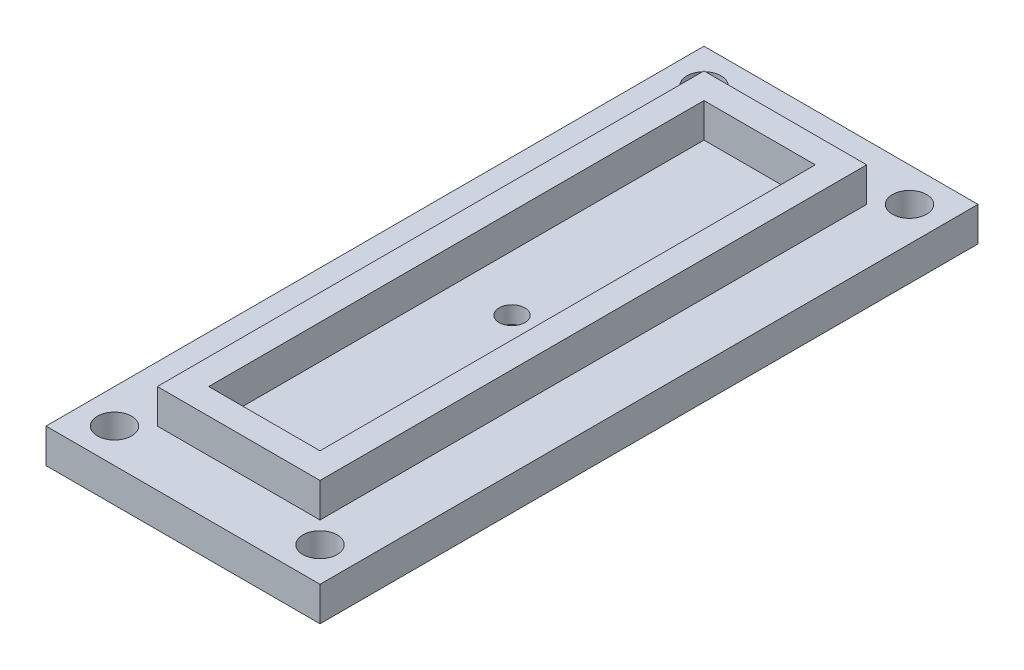
from build123d import *

# Parameters (mm, degrees)
SKETCH1_W               = 16
SKETCH1_H               = 38.42
BOSS_EXTRUDE1_DEPTH     = 2
SKETCH2_W               = 9.5
SKETCH2_H               = 31.92
SKETCH2_W_2             = 6.5
SKETCH2_H_2             = 28.92
EXTRUDE_THIN1_DEPTH     = 2
SKETCH3_R               = 1
CUT_EXTRUDE1_DEPTH      = 22.190188767
MIRROR2_COPY_1_SKETCH_R = 1
MIRROR2_COPY_1_DEPTH    = 22.190188767
MIRROR2_COPY_2_SKETCH_R = 1
MIRROR2_COPY_2_DEPTH    = 22.190188767
CUT_EXTRUDE_THIN1_START = -1
SKETCH2_3_W             = 9.5
SKETCH2_3_H             = 31.92
SKETCH2_3_W_2           = 6.5
SKETCH2_3_H_2           = 28.92
CUT_EXTRUDE_THIN1_DEPTH = 2
CUT_EXTRUDE2_DEPTH      = 21.905121382
CUT_EXTRUDE2_DEPTH_BACK = 21.905121382
SKETCH5_R               = 0.75
SKETCH6_R               = 1.25
CUT_EXTRUDE3_DEPTH      = 1


with BuildPart() as part:
    # Sketch1 → Boss-Extrude1 (new body)
    with BuildSketch(Plane(origin=(0, 0, 0), x_dir=(1, 0, 0), z_dir=(0, 1, 0))):
        Rectangle(SKETCH1_W, SKETCH1_H)
    extrude(amount=BOSS_EXTRUDE1_DEPTH)

    # Sketch2 → Extrude-Thin1 (add)
    with BuildSketch(Plane(origin=(0, 2, 0), x_dir=(1, 0, 0), z_dir=(0, 1, 0))):
        Rectangle(SKETCH2_W, SKETCH2_H)
        Rectangle(SKETCH2_W_2, SKETCH2_H_2, mode=Mode.SUBTRACT)
    extrude(amount=EXTRUDE_THIN1_DEPTH)

    # Sketch3 → Cut-Extrude1 (cut, through all)
    with BuildSketch(Plane.XZ):
        with Locations((6, 17.21)):
            Circle(SKETCH3_R)
    cut_extrude1 = extrude(amount=-CUT_EXTRUDE1_DEPTH, mode=Mode.SUBTRACT)

    # Mirror1: Cut-Extrude1 across plane
    add(cut_extrude1.mirror(Plane(origin=(0, 0, 0), x_dir=(1, 0, 0), z_dir=(0, 0, -1))), mode=Mode.SUBTRACT)

    # Mirror2 copy 1 sketch → Mirror2 copy 1 (cut, through all)
    with BuildSketch(Plane(origin=(0, 0, 0), x_dir=(-1, 0, 0), z_dir=(0, -1, 0))):
        with Locations((6, 17.21)):
            Circle(MIRROR2_COPY_1_SKETCH_R)
    extrude(amount=-MIRROR2_COPY_1_DEPTH, mode=Mode.SUBTRACT)

    # Mirror2 copy 2 sketch → Mirror2 copy 2 (cut, through all)
    with BuildSketch(Plane(origin=(0, 0, 0), x_dir=(-1, 0, 0), z_dir=(0, -1, 0))):
        with Locations((6, -17.21)):
            Circle(MIRROR2_COPY_2_SKETCH_R)
    extrude(amount=-MIRROR2_COPY_2_DEPTH, mode=Mode.SUBTRACT)

    # Sketch2_3 → Cut-Extrude-Thin1 (cut)
    with BuildSketch(Plane(origin=(0, 2, 0), x_dir=(1, 0, 0), z_dir=(0, 1, 0)).offset(CUT_EXTRUDE_THIN1_START)):
        Rectangle(SKETCH2_3_W, SKETCH2_3_H)
        Rectangle(SKETCH2_3_W_2, SKETCH2_3_H_2, mode=Mode.SUBTRACT)
    extrude(amount=-CUT_EXTRUDE_THIN1_DEPTH, mode=Mode.SUBTRACT)

    # Sketch5 → Cut-Extrude2 (cut, two sides: drawn at the far end of the back side and taken through both)
    with BuildSketch(Plane(origin=(0, 2, 0), x_dir=(1, 0, 0), z_dir=(0, 1, 0)).offset(-CUT_EXTRUDE2_DEPTH_BACK)):
        Circle(SKETCH5_R)
    extrude(amount=CUT_EXTRUDE2_DEPTH + CUT_EXTRUDE2_DEPTH_BACK, mode=Mode.SUBTRACT)

    # Sketch6 → Cut-Extrude3 (cut)
    with BuildSketch(Plane.XZ):
        Circle(SKETCH6_R)
    extrude(amount=-CUT_EXTRUDE3_DEPTH, mode=Mode.SUBTRACT)


solid = part.part
